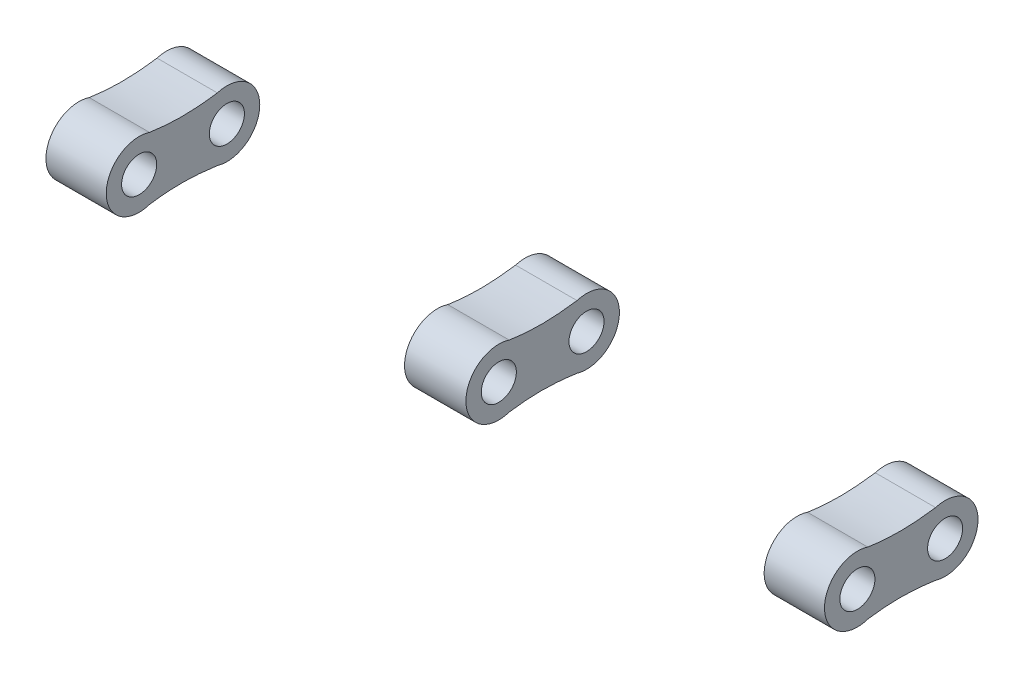
from build123d import *

# Parameters (mm, degrees)
ESBO_O1_R                = 0.4
RESSALTO_EXTRUS_O1_DEPTH = 1.375
ESBO_O2_R                = 0.4
RESSALTO_EXTRUS_O2_DEPTH = 1.375
ESBO_O3_R                = 0.4
RESSALTO_EXTRUS_O3_DEPTH = 1.4


with BuildPart() as part:
    # Esboço1 → Ressalto-extrusão1 (new body)
    with BuildSketch(Plane(origin=(8.875, 0, 0), x_dir=(0, 0, -1), z_dir=(1, 0, 0))):
        with BuildLine():
            ThreePointArc((1.737638655, 0.711356359), (0.75, 0), (1.737638655, -0.711356359))
            add(Edge.make_bspline(
                [(1.737638655, -0.711356359), (2.304737892, -0.628628532), (2.725714325, -0.640882332), (3.28320883, -0.717984393)],
                knots=[0.106827287, 0.106827287, 0.106827287, 0.106827287, 0.900451135, 0.900451135, 0.900451135, 0.900451135], degree=3))
            ThreePointArc((3.28320883, -0.717984393), (4.25, 0), (3.28320883, 0.717984393))
            add(Edge.make_bspline(
                [(1.737638655, 0.711356359), (2.304737892, 0.628628532), (2.725714325, 0.640882332), (3.28320883, 0.717984393)],
                knots=[0.106827287, 0.106827287, 0.106827287, 0.106827287, 0.900451135, 0.900451135, 0.900451135, 0.900451135], degree=3))
        make_face()
        with Locations((1.5, 0)):
            Circle(ESBO_O1_R, mode=Mode.SUBTRACT)
        with Locations((3.5, 0)):
            Circle(ESBO_O1_R, mode=Mode.SUBTRACT)
    extrude(amount=-RESSALTO_EXTRUS_O1_DEPTH)


with BuildPart() as body_2:
    # Esboço2 → Ressalto-extrusão2 (new body)
    with BuildSketch(Plane.ZY.offset(7.5)):
        with BuildLine():
            ThreePointArc((-1.737638655, -0.711356359), (-0.75, 0), (-1.737638655, 0.711356359))
            add(Edge.make_bspline(
                [(-1.737638655, 0.711356359), (-2.304737892, 0.628628532), (-2.725714325, 0.640882332), (-3.28320883, 0.717984393)],
                knots=[0.106827287, 0.106827287, 0.106827287, 0.106827287, 0.900451135, 0.900451135, 0.900451135, 0.900451135], degree=3))
            ThreePointArc((-3.28320883, 0.717984393), (-4.25, 0), (-3.28320883, -0.717984393))
            add(Edge.make_bspline(
                [(-3.28320883, -0.717984393), (-2.725714325, -0.640882332), (-2.304737892, -0.628628532), (-1.737638655, -0.711356359)],
                knots=[0.106827287, 0.106827287, 0.106827287, 0.106827287, 0.900451135, 0.900451135, 0.900451135, 0.900451135], degree=3))
        make_face()
        with Locations((-3.5, 0)):
            Circle(ESBO_O2_R, mode=Mode.SUBTRACT)
        with Locations((-1.5, 0)):
            Circle(ESBO_O2_R, mode=Mode.SUBTRACT)
    extrude(amount=RESSALTO_EXTRUS_O2_DEPTH)


with BuildPart() as body_3:
    # Esboço3 → Ressalto-extrusão3 (new body)
    with BuildSketch(Plane(origin=(-0.7, 0, 0), x_dir=(0, 0, -1), z_dir=(1, 0, 0))):
        with BuildLine():
            ThreePointArc((1.737638655, 0.711356359), (0.75, 0), (1.737638655, -0.711356359))
            add(Edge.make_bspline(
                [(1.737638655, -0.711356359), (2.304737892, -0.628628532), (2.725714325, -0.640882332), (3.28320883, -0.717984393)],
                knots=[0.106827287, 0.106827287, 0.106827287, 0.106827287, 0.900451135, 0.900451135, 0.900451135, 0.900451135], degree=3))
            ThreePointArc((3.28320883, -0.717984393), (4.25, 0), (3.28320883, 0.717984393))
            add(Edge.make_bspline(
                [(3.28320883, 0.717984393), (2.725714325, 0.640882332), (2.304737892, 0.628628532), (1.737638655, 0.711356359)],
                knots=[0.106827287, 0.106827287, 0.106827287, 0.106827287, 0.900451135, 0.900451135, 0.900451135, 0.900451135], degree=3))
        make_face()
        with Locations((3.5, 0)):
            Circle(ESBO_O3_R, mode=Mode.SUBTRACT)
        with Locations((1.5, 0)):
            Circle(ESBO_O3_R, mode=Mode.SUBTRACT)
    extrude(amount=RESSALTO_EXTRUS_O3_DEPTH)


solid = Compound([part.part, body_2.part, body_3.part])
